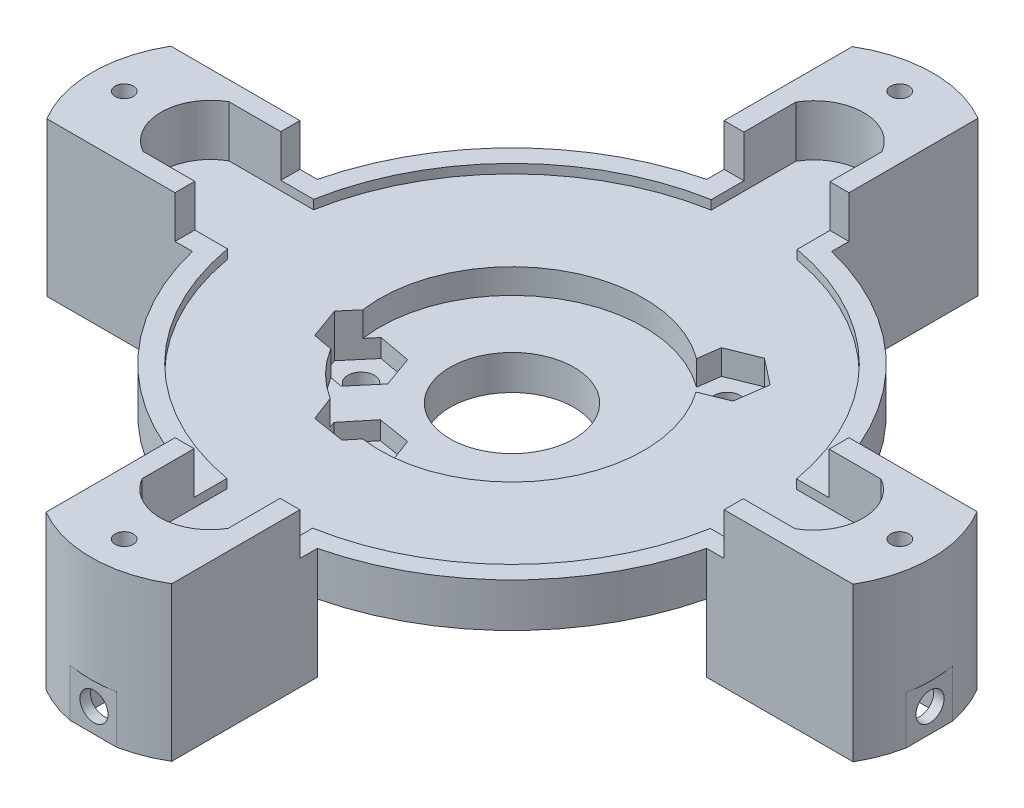
from build123d import *

# Parameters (mm, degrees)
SKETCH1_R                = 32
BOSS_EXTRUDE1_DEPTH      = 8.3
BOSS_EXTRUDE2_DEPTH      = 5.1
BOSS_EXTRUDE2_DEPTH_BACK = 13.5
CUT_EXTRUDE1_START       = -1.1
CUT_EXTRUDE1_DEPTH       = 6.2
SKETCH3_R                = 15.95
CUT_EXTRUDE2_DEPTH       = 3
CUT_EXTRUDE3_REACH       = 11.4
SKETCH4_R                = 7.5
CUT_EXTRUDE4_DEPTH       = 3
CUT_EXTRUDE5_REACH       = 15.4
SKETCH5_3_R              = 1.6
CUT_EXTRUDE6_DEPTH       = 3
CUT_EXTRUDE7_DEPTH       = 3
CUT_EXTRUDE7_DEPTH_BACK  = 2.2
SKETCH10_W               = 66.4
SKETCH10_H               = 66.4
CUT_EXTRUDE8_DEPTH       = 5.1
CUT_EXTRUDE9_REACH       = 20.6
SKETCH11_R               = 1.1
SKETCH12_W               = 4.8
SKETCH12_H               = 5.3
SKETCH12_W_2             = 5.35
SKETCH12_H_2             = 4.8
SKETCH12_H_3             = 5.35
CUT_EXTRUDE10_DEPTH      = 12.6
SKETCH13_W               = 6.3
SKETCH13_H               = 2.5
SKETCH13_W_2             = 2.5
SKETCH13_H_2             = 6.3
CUT_EXTRUDE11_DEPTH      = 6.5
SKETCH14_R               = 1.7
CUT_EXTRUDE12_DEPTH      = 3.5
SKETCH15_W               = 6.3
SKETCH15_H               = 2.5
CUT_EXTRUDE13_DEPTH      = 7.6
CIRPATTERN1_COUNT        = 4
CUT_EXTRUDE14_DEPTH      = 5.8
SKETCH17_R               = 1.7
CUT_EXTRUDE15_DEPTH      = 9
CIRPATTERN9_COUNT        = 4


with BuildPart() as part:
    # Sketch1 → Boss-Extrude1 (new body)
    with BuildSketch(Plane(origin=(0, 0, 0), x_dir=(1, 0, 0), z_dir=(0, 1, 0))):
        Circle(SKETCH1_R)
    extrude(amount=BOSS_EXTRUDE1_DEPTH)

    # Sketch6 → Boss-Extrude2 (add, two sides)
    with BuildSketch(Plane(origin=(0, 8.3, 0), x_dir=(1, 0, 0), z_dir=(0, 1, 0))) as boss_extrude2_sk:
        with BuildLine():
            Line((-7.549820142, 48.696627081), (-7.549820142, 31.096627081))
            Line((-7.549820142, 31.096627081), (7.549820142, 31.096627081))
            Line((7.549820142, 31.096627081), (7.549820142, 48.800854298))
            ThreePointArc((7.549820142, 48.800854298), (-0.014292277, 50.819296248), (-7.549820142, 48.696627081))
        make_face()
        with BuildLine():
            Line((31.096627081, 7.549820142), (31.096627081, -7.549820142))
            Line((31.096627081, -7.549820142), (48.800854298, -7.549820142))
            ThreePointArc((48.800854298, -7.549820142), (50.819296248, 0.014292277), (48.696627081, 7.549820142))
            Line((48.696627081, 7.549820142), (31.096627081, 7.549820142))
        make_face()
        with BuildLine():
            Line((7.549820142, -31.096627081), (-7.549820142, -31.096627081))
            Line((-7.549820142, -31.096627081), (-7.549820142, -48.800854298))
            ThreePointArc((-7.549820142, -48.800854298), (0.014292277, -50.819296248), (7.549820142, -48.696627081))
            Line((7.549820142, -48.696627081), (7.549820142, -31.096627081))
        make_face()
        with BuildLine():
            Line((-31.096627081, -7.549820142), (-31.096627081, 7.549820142))
            Line((-31.096627081, 7.549820142), (-48.800854298, 7.549820142))
            ThreePointArc((-48.800854298, 7.549820142), (-50.819296248, -0.014292277), (-48.696627081, -7.549820142))
            Line((-48.696627081, -7.549820142), (-31.096627081, -7.549820142))
        make_face()
    extrude(amount=BOSS_EXTRUDE2_DEPTH)
    extrude(boss_extrude2_sk.sketch, amount=-BOSS_EXTRUDE2_DEPTH_BACK)

    # Sketch2 → Cut-Extrude1 (cut)
    with BuildSketch(Plane(origin=(0, 8.3, 0), x_dir=(1, 0, 0), z_dir=(0, 1, 0)).offset(CUT_EXTRUDE1_START)):
        with BuildLine():
            Line((29.233353695, -5.244142615), (39.479328292, -5.244142615))
            ThreePointArc((39.479328292, -5.244142615), (42.486002382, -0.044142615), (39.479328292, 5.155857385))
            Line((39.479328292, 5.155857385), (29.249053568, 5.155857385))
            ThreePointArc((29.249053568, 5.155857385), (21.03275072, 20.969344223), (5.244142615, 29.233353695))
            Line((5.244142615, 29.233353695), (5.244142615, 39.479328292))
            ThreePointArc((5.244142615, 39.479328292), (0.044142615, 42.486002382), (-5.155857385, 39.479328292))
            Line((-5.155857385, 39.479328292), (-5.155857385, 29.249053568))
            ThreePointArc((-5.155857385, 29.249053568), (-20.969344223, 21.03275072), (-29.233353695, 5.244142615))
            Line((-29.233353695, 5.244142615), (-39.479328292, 5.244142615))
            ThreePointArc((-39.479328292, 5.244142615), (-42.486002382, 0.044142615), (-39.479328292, -5.155857385))
            Line((-39.479328292, -5.155857385), (-29.249053568, -5.155857385))
            ThreePointArc((-29.249053568, -5.155857385), (-21.03275072, -20.969344223), (-5.244142615, -29.233353695))
            Line((-5.244142615, -29.233353695), (-5.244142615, -39.479328292))
            ThreePointArc((-5.244142615, -39.479328292), (-0.044142615, -42.486002382), (5.155857385, -39.479328292))
            Line((5.155857385, -39.479328292), (5.155857385, -29.249053568))
            ThreePointArc((5.155857385, -29.249053568), (20.969344223, -21.03275072), (29.233353695, -5.244142615))
        make_face()
    extrude(amount=CUT_EXTRUDE1_DEPTH, mode=Mode.SUBTRACT)

    # Sketch3 → Cut-Extrude2 (cut)
    with BuildSketch(Plane(origin=(0, 7.2, 0), x_dir=(1, 0, 0), z_dir=(0, 1, 0))):
        Circle(SKETCH3_R)
    extrude(amount=-CUT_EXTRUDE2_DEPTH, mode=Mode.SUBTRACT)

    # Sketch4 → Cut-Extrude3 (cut, up to next)
    with BuildSketch(Plane(origin=(0, 4.2, 0), x_dir=(1, 0, 0), z_dir=(0, 1, 0)), mode=Mode.PRIVATE) as cut_extrude3_sk1:
        Circle(SKETCH4_R)
    cut_extrude3_tool1 = extrude(cut_extrude3_sk1.sketch, amount=-CUT_EXTRUDE3_REACH, mode=Mode.PRIVATE) & part.part
    add(cut_extrude3_tool1.solids().sort_by_distance((0, 4.2, 0))[0], mode=Mode.SUBTRACT)

    # Sketch5 → Cut-Extrude4 (cut)
    with BuildSketch(Plane.XZ):
        with BuildLine():
            Line((31.096627081, -7.549820142), (31.096627081, 7.549820142))
            ThreePointArc((31.096627081, 7.549820142), (22.627416998, 22.627416998), (7.549820142, 31.096627081))
            Line((7.549820142, 31.096627081), (-7.549820142, 31.096627081))
            ThreePointArc((-7.549820142, 31.096627081), (-22.627416998, 22.627416998), (-31.096627081, 7.549820142))
            Line((-31.096627081, 7.549820142), (-31.096627081, -7.549820142))
            ThreePointArc((-31.096627081, -7.549820142), (-22.627416998, -22.627416998), (-7.549820142, -31.096627081))
            Line((-7.549820142, -31.096627081), (7.549820142, -31.096627081))
            ThreePointArc((7.549820142, -31.096627081), (22.627416998, -22.627416998), (31.096627081, -7.549820142))
        make_face()
        with BuildLine():
            Line((-19.75, 4.693346354), (-19.75, 19.75))
            Line((-19.75, 19.75), (-4.693346354, 19.75))
            ThreePointArc((-4.693346354, 19.75), (0, 20.3), (4.693346354, 19.75))
            Line((4.693346354, 19.75), (19.75, 19.75))
            Line((19.75, 19.75), (19.75, 4.693346354))
            ThreePointArc((19.75, 4.693346354), (20.162031148, 2.36273147), (20.3, 0))
            ThreePointArc((20.3, 0), (20.162031148, -2.36273147), (19.75, -4.693346354))
            Line((19.75, -4.693346354), (19.75, -19.75))
            Line((19.75, -19.75), (4.693346354, -19.75))
            ThreePointArc((4.693346354, -19.75), (0, -20.3), (-4.693346354, -19.75))
            Line((-4.693346354, -19.75), (-19.75, -19.75))
            Line((-19.75, -19.75), (-19.75, -4.693346354))
            ThreePointArc((-19.75, -4.693346354), (-20.3, 0), (-19.75, 4.693346354))
        make_face(mode=Mode.SUBTRACT)
        with BuildLine():
            ThreePointArc((-4.693346354, -19.75), (-14.354267658, -14.354267658), (-19.75, -4.693346354))
            Line((-19.75, -4.693346354), (-19.75, -19.75))
            Line((-19.75, -19.75), (-4.693346354, -19.75))
        make_face()
        with BuildLine():
            Line((19.75, -19.75), (19.75, -4.693346354))
            ThreePointArc((19.75, -4.693346354), (18.852722691, -7.527605672), (17.551109289, -10.200419732))
            ThreePointArc((17.551109289, -10.200419732), (17.704832135, -10.971653781), (17.756368191, -11.756368191))
            ThreePointArc((17.756368191, -11.756368191), (15.407690503, -16.517444265), (10.200419732, -17.551109289))
            ThreePointArc((10.200419732, -17.551109289), (7.527605672, -18.852722691), (4.693346354, -19.75))
            Line((4.693346354, -19.75), (19.75, -19.75))
        make_face()
        with BuildLine():
            Line((19.75, 19.75), (4.693346354, 19.75))
            ThreePointArc((4.693346354, 19.75), (14.354267658, 14.354267658), (19.75, 4.693346354))
            Line((19.75, 4.693346354), (19.75, 19.75))
        make_face()
        with BuildLine():
            Line((-4.693346354, 19.75), (-19.75, 19.75))
            Line((-19.75, 19.75), (-19.75, 4.693346354))
            ThreePointArc((-19.75, 4.693346354), (-14.354267658, 14.354267658), (-4.693346354, 19.75))
        make_face()
    extrude(amount=-CUT_EXTRUDE4_DEPTH, mode=Mode.SUBTRACT)

    # Sketch5_3 → Cut-Extrude5 (cut, up to next)
    with BuildSketch(Plane.XZ, mode=Mode.PRIVATE) as cut_extrude5_sk1:
        with Locations((13.010764774, -13.010764774)):
            Circle(SKETCH5_3_R)
    cut_extrude5_tool1 = extrude(cut_extrude5_sk1.sketch, amount=-CUT_EXTRUDE5_REACH, mode=Mode.PRIVATE) & part.part
    add(cut_extrude5_tool1.solids().sort_by_distance((13.010765, 0, -13.010765))[0], mode=Mode.SUBTRACT)
    # Sketch5_3 → Cut-Extrude5 (cut, up to next)
    with BuildSketch(Plane.XZ, mode=Mode.PRIVATE) as cut_extrude5_sk2:
        with Locations((-4.808326112, 13.435028843)):
            Circle(SKETCH5_3_R)
    cut_extrude5_tool2 = extrude(cut_extrude5_sk2.sketch, amount=-CUT_EXTRUDE5_REACH, mode=Mode.PRIVATE) & part.part
    add(cut_extrude5_tool2.solids().sort_by_distance((-4.808326, 0, 13.435029))[0], mode=Mode.SUBTRACT)
    # Sketch5_3 → Cut-Extrude5 (cut, up to next)
    with BuildSketch(Plane.XZ, mode=Mode.PRIVATE) as cut_extrude5_sk3:
        with Locations((-13.435028843, 4.808326112)):
            Circle(SKETCH5_3_R)
    cut_extrude5_tool3 = extrude(cut_extrude5_sk3.sketch, amount=-CUT_EXTRUDE5_REACH, mode=Mode.PRIVATE) & part.part
    add(cut_extrude5_tool3.solids().sort_by_distance((-13.435029, 0, 4.808326))[0], mode=Mode.SUBTRACT)

    # Sketch7 → Cut-Extrude6 (cut)
    with BuildSketch(Plane(origin=(0, 7.2, 0), x_dir=(1, 0, 0), z_dir=(0, 1, 0))):
        Polygon((9.868287963, 15.459200907), (9.319118478, 11.513518092), (12.461595289, 9.065081959), (16.153241584, 10.562328641), (16.70241107, 14.508011456), (13.559934259, 16.956447589), align=None)
    extrude(amount=-CUT_EXTRUDE6_DEPTH, mode=Mode.SUBTRACT)

    # Sketch9 → Cut-Extrude7 (cut, two sides)
    with BuildSketch(Plane(origin=(0, 4.2, 0), x_dir=(1, 0, 0), z_dir=(0, 1, 0))) as cut_extrude7_sk:
        Polygon((-6.219522179, -9.709639512), (-8.740205944, -12.794465821), (-7.329009878, -16.519855151), (-3.397130045, -17.160418173), (-0.87644628, -14.075591864), (-2.287642346, -10.350202534), align=None)
        Polygon((-10.859589106, -1.769064662), (-14.779386599, -1.058299149), (-17.354826336, -4.097560599), (-16.010468579, -7.847587562), (-12.090671086, -8.558353075), (-9.51523135, -5.519091625), align=None)
    extrude(amount=CUT_EXTRUDE7_DEPTH, mode=Mode.SUBTRACT)
    extrude(cut_extrude7_sk.sketch, amount=-CUT_EXTRUDE7_DEPTH_BACK, mode=Mode.SUBTRACT)

    # Sketch10 → Cut-Extrude8 (cut)
    with BuildSketch(Plane(origin=(0, 8.3, 0), x_dir=(1, 0, 0), z_dir=(0, 1, 0))):
        Rectangle(SKETCH10_W, SKETCH10_H)
    extrude(amount=CUT_EXTRUDE8_DEPTH, mode=Mode.SUBTRACT)

    # Sketch11 → Cut-Extrude9 (cut, up to next)
    with BuildSketch(Plane(origin=(0, 13.4, 0), x_dir=(1, 0, 0), z_dir=(0, 1, 0)), mode=Mode.PRIVATE) as cut_extrude9_sk1:
        with Locations((0.000179858, -46.896627081)):
            Circle(SKETCH11_R)
    cut_extrude9_tool1 = extrude(cut_extrude9_sk1.sketch, amount=-CUT_EXTRUDE9_REACH, mode=Mode.PRIVATE) & part.part
    add(cut_extrude9_tool1.solids().sort_by_distance((0.00018, 13.4, 46.896627))[0], mode=Mode.SUBTRACT)
    # Sketch11 → Cut-Extrude9 (cut, up to next)
    with BuildSketch(Plane(origin=(0, 13.4, 0), x_dir=(1, 0, 0), z_dir=(0, 1, 0)), mode=Mode.PRIVATE) as cut_extrude9_sk2:
        with Locations((-46.896627081, 0.000179858)):
            Circle(SKETCH11_R)
    cut_extrude9_tool2 = extrude(cut_extrude9_sk2.sketch, amount=-CUT_EXTRUDE9_REACH, mode=Mode.PRIVATE) & part.part
    add(cut_extrude9_tool2.solids().sort_by_distance((-46.896627, 13.4, -0.00018))[0], mode=Mode.SUBTRACT)
    # Sketch11 → Cut-Extrude9 (cut, up to next)
    with BuildSketch(Plane(origin=(0, 13.4, 0), x_dir=(1, 0, 0), z_dir=(0, 1, 0)), mode=Mode.PRIVATE) as cut_extrude9_sk3:
        with Locations((0.000179858, 46.896627081)):
            Circle(SKETCH11_R)
    cut_extrude9_tool3 = extrude(cut_extrude9_sk3.sketch, amount=-CUT_EXTRUDE9_REACH, mode=Mode.PRIVATE) & part.part
    add(cut_extrude9_tool3.solids().sort_by_distance((0.00018, 13.4, -46.896627))[0], mode=Mode.SUBTRACT)
    # Sketch11 → Cut-Extrude9 (cut, up to next)
    with BuildSketch(Plane(origin=(0, 13.4, 0), x_dir=(1, 0, 0), z_dir=(0, 1, 0)), mode=Mode.PRIVATE) as cut_extrude9_sk4:
        with Locations((46.896627081, 0.000179858)):
            Circle(SKETCH11_R)
    cut_extrude9_tool4 = extrude(cut_extrude9_sk4.sketch, amount=-CUT_EXTRUDE9_REACH, mode=Mode.PRIVATE) & part.part
    add(cut_extrude9_tool4.solids().sort_by_distance((46.896627, 13.4, -0.00018))[0], mode=Mode.SUBTRACT)

    # Sketch12 → Cut-Extrude10 (cut)
    with BuildSketch(Plane.XZ.offset(5.2)):
        with Locations((-46.896627081, -0.000179858)):
            Rectangle(SKETCH12_W, SKETCH12_H)
        with Locations((0.000179858, -46.896627081)):
            Rectangle(SKETCH12_W_2, SKETCH12_H_2)
        with Locations((0.000179858, 46.896627081)):
            Rectangle(SKETCH12_W_2, SKETCH12_H_2)
        with Locations((46.896627081, -0.000179858)):
            Rectangle(SKETCH12_W, SKETCH12_H_3)
    extrude(amount=-CUT_EXTRUDE10_DEPTH, mode=Mode.SUBTRACT)

    # Sketch13 → Cut-Extrude11 (cut)
    with BuildSketch(Plane.XZ.offset(5.2)):
        with Locations((0.000179858, 40.846627081)):
            Rectangle(SKETCH13_W, SKETCH13_H)
        with Locations((40.846627081, -0.000179858)):
            Rectangle(SKETCH13_W_2, SKETCH13_H_2)
        Polygon((3.199820142, -42.096134201), (3.150179858, -39.596627081), (-3.149820142, -39.596627081), (-3.100179858, -42.096134201), align=None)
        Polygon((-42.096627055, -3.149820142), (-39.596627081, -3.150179858), (-39.596627081, 3.149820142), (-42.096627055, 3.150179858), align=None)
    extrude(amount=-CUT_EXTRUDE11_DEPTH, mode=Mode.SUBTRACT)

    # Sketch14 → Cut-Extrude12 (cut)
    with BuildSketch(Plane.XZ.offset(5.2)):
        with Locations((0.000179858, 35.196627081)):
            Circle(SKETCH14_R)
        with Locations((35.196986798, -0.000179858)):
            Circle(SKETCH14_R)
        with Locations((0.000179858, -35.196986798)):
            Circle(SKETCH14_R)
        with Locations((-35.196627081, -0.000179858)):
            Circle(SKETCH14_R)
    extrude(amount=-CUT_EXTRUDE12_DEPTH, mode=Mode.SUBTRACT)

    # Sketch15 → Cut-Extrude13 (cut)
    with BuildSketch(Plane(origin=(-31.096627081, 0, 0), x_dir=(0, 0, -1), z_dir=(1, 0, 0))):
        with Locations((0.000179858, -0.45)):
            Rectangle(SKETCH15_W, SKETCH15_H)
    cut_extrude13 = extrude(amount=-CUT_EXTRUDE13_DEPTH, mode=Mode.SUBTRACT)

    # CirPattern1: Cut-Extrude13 ×4 about axis
    cirpattern1_axis = Axis((0, 0, 0), (0, 1, 0))
    for i in range(1, CIRPATTERN1_COUNT):
        add(cut_extrude13.rotate(cirpattern1_axis, i * 360 / CIRPATTERN1_COUNT), mode=Mode.SUBTRACT)

    # Sketch16 → Cut-Extrude14 (cut)
    with BuildSketch(Plane.XZ.offset(5.2)):
        with BuildLine():
            Line((50.552370518, 2.8878642), (50.552370518, -2.7121358))
            ThreePointArc((50.552370518, -2.7121358), (50.819648818, 0.0878642), (50.552370518, 2.8878642))
        make_face()
        with BuildLine():
            Line((2.8878642, -50.552370518), (-2.7121358, -50.552370518))
            ThreePointArc((-2.7121358, -50.552370518), (0.0878642, -50.819648818), (2.8878642, -50.552370518))
        make_face()
        with BuildLine():
            Line((-50.552370518, -2.8878642), (-50.552370518, 2.7121358))
            ThreePointArc((-50.552370518, 2.7121358), (-50.819648818, -0.0878642), (-50.552370518, -2.8878642))
        make_face()
        with BuildLine():
            Line((-2.8878642, 50.552370518), (2.7121358, 50.552370518))
            ThreePointArc((2.7121358, 50.552370518), (-0.0878642, 50.819648818), (-2.8878642, 50.552370518))
        make_face()
    extrude(amount=-CUT_EXTRUDE14_DEPTH, mode=Mode.SUBTRACT)

    # Sketch17 → Cut-Extrude15 (cut)
    with BuildSketch(Plane(origin=(50.552370518, 0, 0), x_dir=(0, 0, -1), z_dir=(1, 0, 0))):
        with Locations((0.000179858, -2.3)):
            Circle(SKETCH17_R)
    cut_extrude15 = extrude(amount=-CUT_EXTRUDE15_DEPTH, mode=Mode.SUBTRACT)

    # CirPattern9: Cut-Extrude15 ×4 about axis
    cirpattern9_axis = Axis((0, 0, 0), (0, 1, 0))
    for i in range(1, CIRPATTERN9_COUNT):
        add(cut_extrude15.rotate(cirpattern9_axis, i * 360 / CIRPATTERN9_COUNT), mode=Mode.SUBTRACT)


solid = part.part
